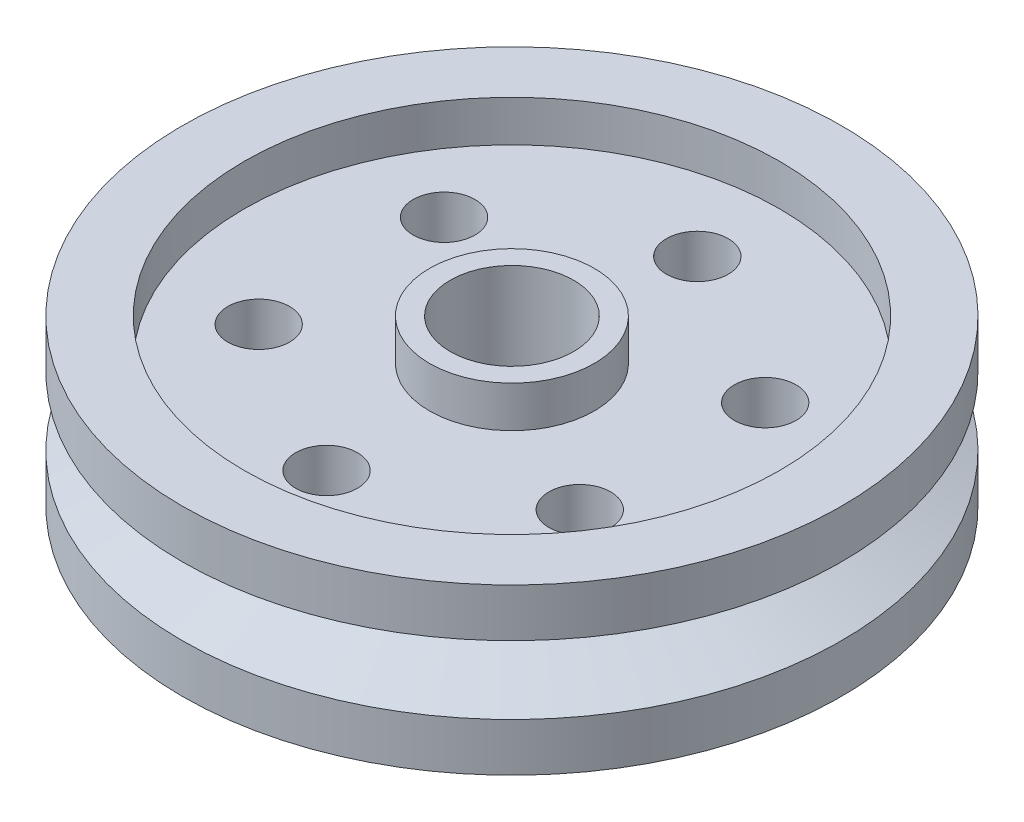
from build123d import *

# Parameters (mm, degrees)
SKETCH2_R          = 41.275
SKETCH2_R_2        = 12.7
CUT_EXTRUDE1_DEPTH = 6.35
SKETCH3_R          = 9.525
CUT_EXTRUDE2_DEPTH = 13.7
SKETCH5_R          = 4.7625
CUT_EXTRUDE3_DEPTH = 7.35
CIRPATTERN1_COUNT  = 6


with BuildPart() as part:
    # Sketch1 → Revolve1 (revolve)
    with BuildSketch(Plane.XY):
        Polygon((0, 0), (0, 12.7), (50.8, 12.7), (50.8, 5.260512242), (38.1, 0), align=None)
    revolve(axis=Axis((0, 218.832128387, 0), (0, -1, 0)))

    # Sketch2 → Cut-Extrude1 (cut)
    with BuildSketch(Plane(origin=(0, 12.7, 0), x_dir=(1, 0, 0), z_dir=(0, 1, 0))):
        Circle(SKETCH2_R)
        Circle(SKETCH2_R_2, mode=Mode.SUBTRACT)
    extrude(amount=-CUT_EXTRUDE1_DEPTH, mode=Mode.SUBTRACT)

    # Sketch3 → Cut-Extrude2 (cut, through all)
    with BuildSketch(Plane(origin=(0, 12.7, 0), x_dir=(1, 0, 0), z_dir=(0, 1, 0))):
        Circle(SKETCH3_R)
    extrude(amount=-CUT_EXTRUDE2_DEPTH, mode=Mode.SUBTRACT)

    # Sketch5 → Cut-Extrude3 (cut, through all)
    with BuildSketch(Plane(origin=(0, 6.35, 0), x_dir=(1, 0, 0), z_dir=(0, 1, 0))):
        with Locations((0, 28.575)):
            Circle(SKETCH5_R)
    cut_extrude3 = extrude(amount=-CUT_EXTRUDE3_DEPTH, mode=Mode.SUBTRACT)

    # CirPattern1: Cut-Extrude3 ×6 about axis
    cirpattern1_axis = Axis((0, 0, 0), (0, 1, 0))
    for i in range(1, CIRPATTERN1_COUNT):
        add(cut_extrude3.rotate(cirpattern1_axis, i * 360 / CIRPATTERN1_COUNT), mode=Mode.SUBTRACT)

    # Mirror1: part across plane


with BuildPart() as part_1:
    add(part.part)
    add(part.part.mirror(Plane.ZX))


solid = part_1.part
